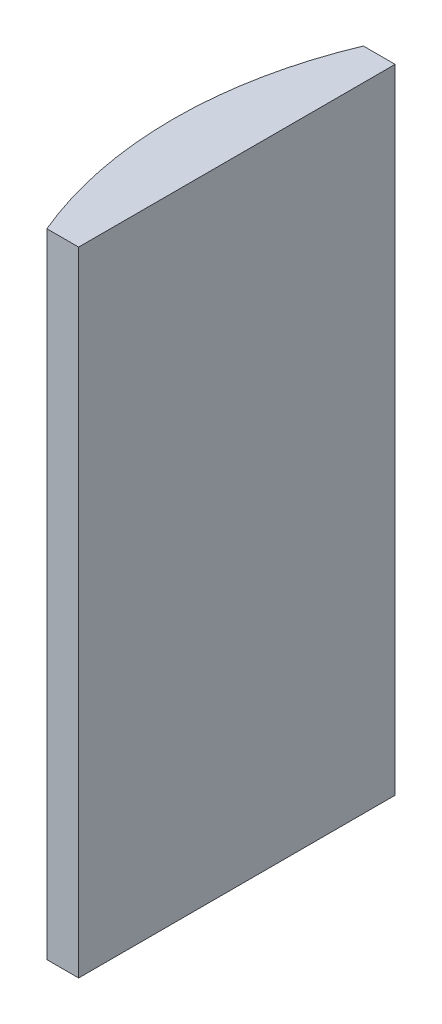
from build123d import *

# Parameters (mm, degrees)
EXTRUDE_1_DEPTH = 40


with BuildPart() as part:
    # 草图1 → 凸台-拉伸1 (new body)
    with BuildSketch(Plane(origin=(0, 0, 0), x_dir=(1, 0, 0), z_dir=(0, 1, 0))):
        with BuildLine():
            Line((-19.48221373, 10), (-17.474795665, 10))
            Line((-17.474795665, 10), (-17.474795665, -10))
            Line((-17.474795665, -10), (-19.48221373, -10))
            ThreePointArc((-19.48221373, -10), (-21.494795665, 0), (-19.48221373, 10))
        make_face()
    extrude(amount=EXTRUDE_1_DEPTH)


solid = part.part
